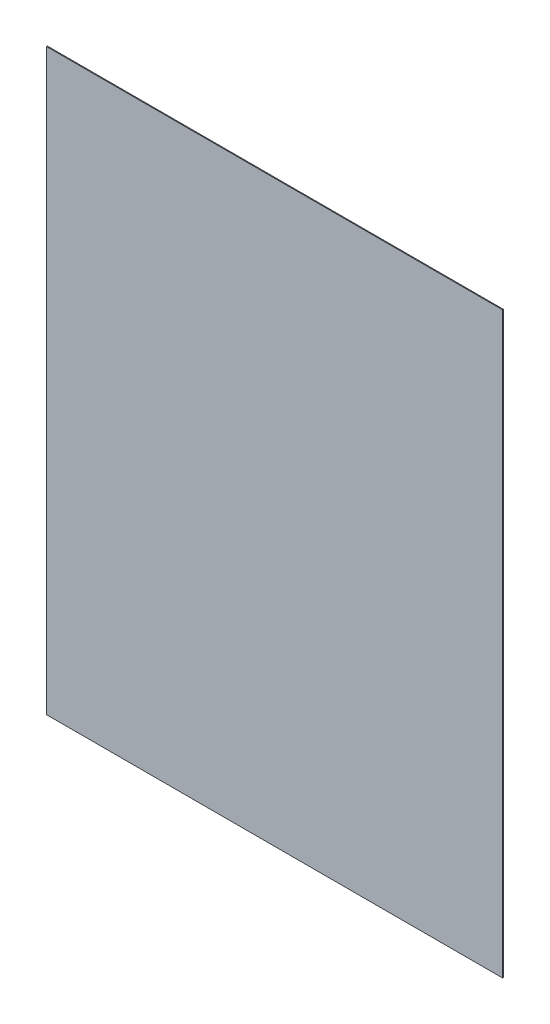
from build123d import *

# Parameters (mm, degrees)
SKETCH1_W           = 521
SKETCH1_H           = 661
BOSS_EXTRUDE1_DEPTH = 1


with BuildPart() as part:
    # Sketch1 → Boss-Extrude1 (new body)
    with BuildSketch(Plane.XY):
        Rectangle(SKETCH1_W, SKETCH1_H)
    extrude(amount=BOSS_EXTRUDE1_DEPTH)


solid = part.part
